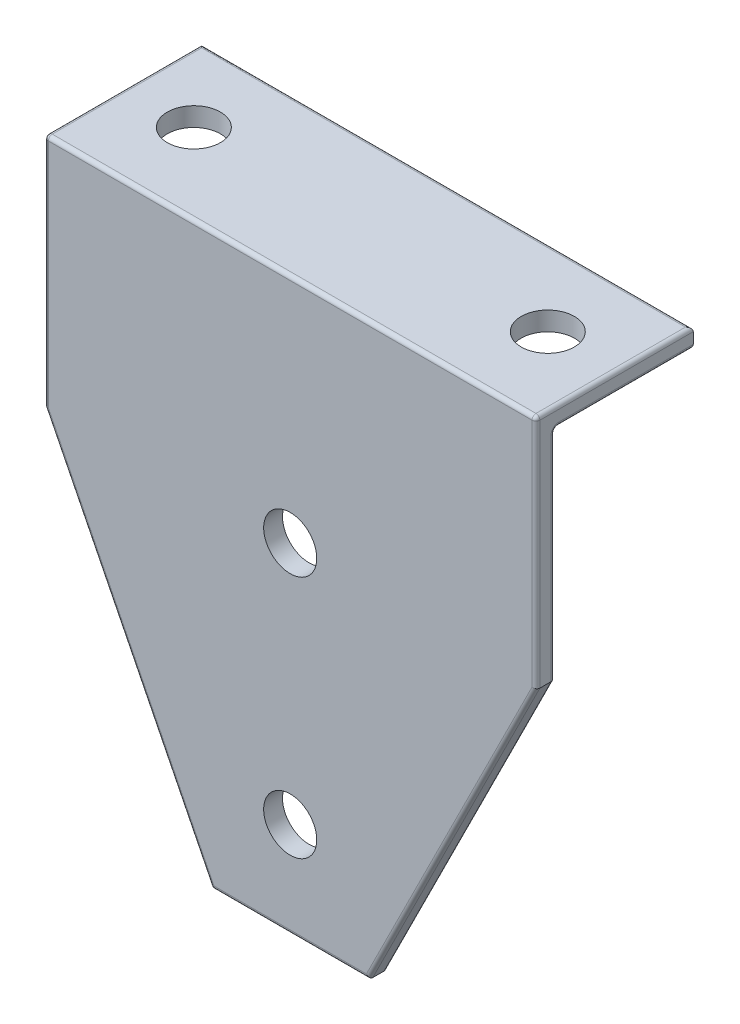
from build123d import *

# Parameters (mm, degrees)
SALIENTE_EXTRUIR1_DEPTH       = 4.8
CROQUIS2_W                    = 125
CROQUIS2_H                    = 4.8
SALIENTE_EXTRUIR2_DEPTH       = 35.2
REDONDEO1_R                   = 1
TALADRO_DE_MARGEN_PARA_M121_D = 13.5
TALADRO_DE_MARGEN_PARA_M122_D = 13.5


with BuildPart() as part:
    # Croquis1 → Saliente-Extruir1 (new body)
    with BuildSketch(Plane.XY):
        Polygon((-912.5, -63.6), (-912.5, -123.6), (-870, -208.6), (-830, -208.6), (-787.5, -123.6), (-787.5, -63.6), align=None)
    extrude(amount=-SALIENTE_EXTRUIR1_DEPTH)

    # Croquis2 → Saliente-Extruir2 (add)
    with BuildSketch(Plane(origin=(0, 0, -4.8), x_dir=(-1, 0, 0), z_dir=(0, 0, -1))):
        with Locations((850, -66)):
            Rectangle(CROQUIS2_W, CROQUIS2_H)
    extrude(amount=SALIENTE_EXTRUIR2_DEPTH)

    # Redondeo1
    redondeo1_edges = [part.edges().sort_by_distance(p)[0] for p in [
        (-912.5, -63.6, -20),
        (-787.5, -63.6, -20),
        (-912.5, -96, -4.8),
        (-891.25, -166.1, -4.8),
        (-850, -68.4, -4.8),
        (-787.5, -68.4, -22.4),
        (-912.5, -68.4, -22.4),
        (-850, -68.4, -40),
        (-850, -63.6, -40),
        (-850, -208.6, -4.8),
        (-808.75, -166.1, -4.8),
        (-850, -208.6, 0),
        (-891.25, -166.1, 0),
        (-912.5, -93.6, 0),
        (-850, -63.6, 0),
        (-787.5, -93.6, 0),
        (-808.75, -166.1, 0),
        (-787.5, -96, -4.8),
    ]]
    fillet(redondeo1_edges, radius=REDONDEO1_R)

    # Taladro de margen para M121 (through all)
    with Locations(Plane(origin=(0, -63.6, 0), x_dir=(1, 0, 0), z_dir=(0, 1, 0))):
        with Locations((-895, 20.5), (-805, 20.5)):
            Hole(TALADRO_DE_MARGEN_PARA_M121_D / 2)

    # Taladro de margen para M122 (through all)
    with Locations(Plane.XY):
        with Locations((-850, -122.4), (-850, -184.4)):
            Hole(TALADRO_DE_MARGEN_PARA_M122_D / 2)


solid = part.part
